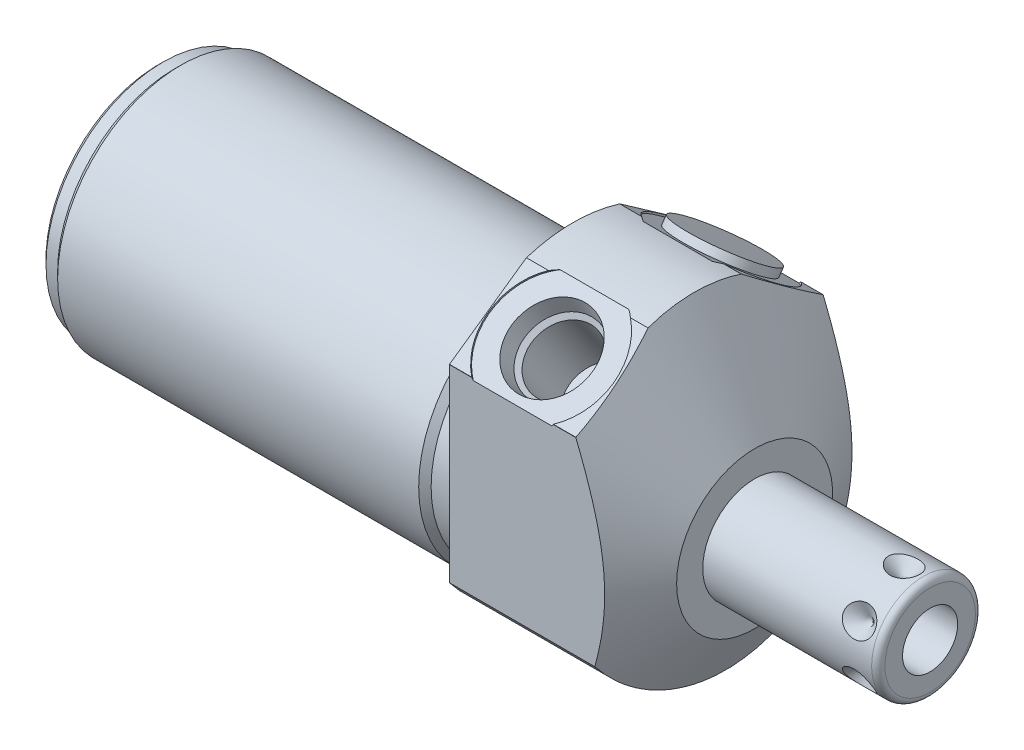
from build123d import *

# Parameters (mm, degrees)
SKETCH1_R           = 23.8125
EXTRUDE1_DEPTH      = 27.7876
EXTRUDE1_DEPTH_BACK = 63.5
CUT_EXTRUDE1_REACH  = 65.5
SKETCH2_R           = 23.8125
SKETCH2_R_2         = 18.8595
CUT_EXTRUDE3_START  = -27.7876
SKETCH4_R           = 28.575
CUT_EXTRUDE3_DEPTH  = 27.7876
SKETCH18_R          = 9.525
CUT_EXTRUDE4_DEPTH  = 0.254
SKETCH19_R          = 9.525
CUT_EXTRUDE5_DEPTH  = 0.254
CHAMFER1_SIZE       = 0.762
SKETCH15_R          = 6.9469
EXTRUDE2_DEPTH      = 1.27
CIRPATTERN1_COUNT   = 6


with BuildPart() as part:
    # Sketch1 → Extrude1 (new body, two sides)
    with BuildSketch(Plane(origin=(0, 0, 0), x_dir=(0, 0, -1), z_dir=(1, 0, 0))) as extrude1_sk:
        Circle(SKETCH1_R)
    extrude(amount=EXTRUDE1_DEPTH)
    extrude(extrude1_sk.sketch, amount=-EXTRUDE1_DEPTH_BACK)

    # Sketch2 → Cut-Extrude1 (cut, up to next)
    with BuildSketch(Plane(origin=(0, 0, 0), x_dir=(0, 0, -1), z_dir=(1, 0, 0)), mode=Mode.PRIVATE) as cut_extrude1_sk1:
        Circle(SKETCH2_R)
        with Locations((0, -4.191)):
            Circle(SKETCH2_R_2, mode=Mode.SUBTRACT)
    cut_extrude1_tool1 = extrude(cut_extrude1_sk1.sketch, amount=-CUT_EXTRUDE1_REACH, mode=Mode.PRIVATE) & part.part
    add(cut_extrude1_tool1.solids().sort_by_distance((0, 0, 23.138981))[0], mode=Mode.SUBTRACT)

    # Sketch4 → Cut-Extrude3 (cut)
    with BuildSketch(Plane.ZY.offset(CUT_EXTRUDE3_START)):
        Circle(SKETCH4_R)
        with BuildLine():
            Line((18.923, -14.455283714), (18.923, 14.465869871))
            Line((18.923, 14.465869871), (0, 27.715897117))
            Line((0, 27.715897117), (-18.923, 14.465869871))
            Line((-18.923, 14.465869871), (-18.923, -14.455283714))
            ThreePointArc((-18.923, -14.455283714), (0, -23.8125), (18.923, -14.455283714))
        make_face(mode=Mode.SUBTRACT)
    extrude(amount=CUT_EXTRUDE3_DEPTH, mode=Mode.SUBTRACT)

    # Sketch6 → Cut-Revolve2 (revolve, cut)
    with BuildSketch(Plane.XY, mode=Mode.PRIVATE) as cut_revolve2_sk:
        Polygon((4.764025965, 47.625), (27.7876, 7.747), (27.7876, 47.625), align=None)
    revolve(cut_revolve2_sk.sketch.rotate(Axis((3.612847264, -4.191, 0), (1, 0, 0)), 270), axis=Axis((3.612847264, -4.191, 0), (1, 0, 0)), mode=Mode.SUBTRACT)  # turned: the seam where the file's is

    # S2D0002 → Cut-Revolve3 (revolve, cut)
    with BuildSketch(Plane(origin=(9.652, 18.394824642, 12.869035589), x_dir=(0, 0.573576436, -0.819152044), z_dir=(1, 0, 0))):
        Polygon((0, 0), (6.1849, 0), (5.642306865, -2.5527), (4.9784, -3.216606865), (4.9784, -13.462), (0, -13.462), align=None)
    revolve(axis=Axis((9.652, 6.816028581, 4.761475303), (0, 0.819152044, 0.573576436)), mode=Mode.SUBTRACT)

    # Sketch8 → Cut-Revolve4 (revolve, cut)
    with BuildSketch(Plane(origin=(9.652, 18.394824642, -12.869035589), x_dir=(0, -0.573576436, -0.819152044), z_dir=(1, 0, 0))):
        Polygon((0, 0), (6.1849, 0), (5.642306865, -2.5527), (4.9784, -3.216606865), (4.9784, -13.462), (0, -13.462), align=None)
    revolve(axis=Axis((9.652, 6.816028581, -4.761475303), (0, 0.819152044, -0.573576436)), mode=Mode.SUBTRACT)

    # Sketch18 → Cut-Extrude4 (cut)
    with BuildSketch(Plane(origin=(0, 18.59764611, 13.022211999), x_dir=(1, 0, 0), z_dir=(0, 0.819152044, 0.573576436))):
        with Locations((9.652, 0.009141155)):
            Circle(SKETCH18_R)
    extrude(amount=-CUT_EXTRUDE4_DEPTH, mode=Mode.SUBTRACT)

    # Sketch19 → Cut-Extrude5 (cut)
    with BuildSketch(Plane(origin=(0, 18.59764611, -13.022211999), x_dir=(1, 0, 0), z_dir=(0, 0.819152044, -0.573576436))):
        with Locations((9.652, -0.009141155)):
            Circle(SKETCH19_R)
    extrude(amount=-CUT_EXTRUDE5_DEPTH, mode=Mode.SUBTRACT)

    # Sketch10 → Cut-Revolve6 (revolve, cut)
    with BuildSketch(Plane.XY, mode=Mode.PRIVATE) as cut_revolve6_sk:
        Polygon((0, 14.6685), (0, 13.716), (-3.81, 13.716), (-4.7625, 14.6685), align=None)
    revolve(cut_revolve6_sk.sketch.rotate(Axis((-5.000625, -4.191, 0), (1, 0, 0)), 90), axis=Axis((-5.000625, -4.191, 0), (1, 0, 0)), mode=Mode.SUBTRACT)  # turned: the seam where the file's is

    # Sketch12 → Cut-Revolve8 (revolve, cut)
    with BuildSketch(Plane.XY, mode=Mode.PRIVATE) as cut_revolve8_sk:
        Polygon((-63.5, 14.6685), (-63.5, 13.716), (-60.96, 13.716), (-60.0075, 14.6685), align=None)
    revolve(cut_revolve8_sk.sketch.rotate(Axis((-63.674625, -4.191, 0), (1, 0, 0)), 90), axis=Axis((-63.674625, -4.191, 0), (1, 0, 0)), mode=Mode.SUBTRACT)  # turned: the seam where the file's is

    # Chamfer1
    chamfer1_edges = [part.edges().sort_by_distance(p)[0] for p in [
        (-63.5, -4.191, -17.907),
    ]]
    chamfer(chamfer1_edges, length=CHAMFER1_SIZE)

    # Sketch13 → Revolve1 (revolve)
    with BuildSketch(Plane(origin=(0, 0, 0), x_dir=(0, -1, 0), z_dir=(0, 0, 1)), mode=Mode.PRIVATE) as revolve1_sk:
        with BuildLine():
            Line((4.191, 27.7876), (4.191, 54.6354))
            Line((4.191, 54.6354), (11.1125, 54.6354))
            ThreePointArc((11.1125, 54.6354), (11.83092049, 54.33782049), (12.1285, 53.6194))
            Line((12.1285, 53.6194), (12.1285, 27.7876))
            Line((12.1285, 27.7876), (4.191, 27.7876))
        make_face()
    revolve(revolve1_sk.sketch.rotate(Axis((26.44521, -4.191, 0), (1, 0, 0)), 270), axis=Axis((26.44521, -4.191, 0), (1, 0, 0)))  # turned: the seam where the file's is

    # S2D0001 → Cut-Revolve9 (revolve, cut)
    with BuildSketch(Plane(origin=(54.6354, -8.4074, 0), x_dir=(0, -1, 0), z_dir=(0, 0, 1)), mode=Mode.PRIVATE) as cut_revolve9_sk:
        Polygon((0, 0), (0, -15.24), (-4.2164, -17.773468714), (-4.2164, 0), align=None)
    revolve(cut_revolve9_sk.sketch.rotate(Axis((35.97325785, -4.191, 0), (1, 0, 0)), 270), axis=Axis((35.97325785, -4.191, 0), (1, 0, 0)), mode=Mode.SUBTRACT)  # turned: the seam where the file's is

    # Sketch15 → Extrude2 (add)
    with BuildSketch(Plane(origin=(27.7876, 18.389581491, -12.876523585), x_dir=(0, -0.573576436, -0.819152044), z_dir=(0, -0.819152044, 0.573576436))):
        with Locations((-0.009141155, -18.1356)):
            Circle(SKETCH15_R)
    extrude(amount=-EXTRUDE2_DEPTH)

    # Sketch16 → Cut-Revolve10 (revolve, cut)
    with BuildSketch(Plane(origin=(50.673, 3.7465, 0), x_dir=(-1, 0, 0), z_dir=(0, 0, -1)), mode=Mode.PRIVATE) as cut_revolve10_sk:
        Polygon((0, 0), (2.413, 0), (0, -2.413), align=None)
    cut_revolve10 = revolve(cut_revolve10_sk.sketch.rotate(Axis((50.673, -1.324519499, 0), (0, 1, 0)), 90), axis=Axis((50.673, -1.324519499, 0), (0, 1, 0)), mode=Mode.SUBTRACT)  # turned: the seam where the file's is

    # CirPattern1: Cut-Revolve10 ×6 about axis
    cirpattern1_axis = Axis((26.44521, -4.191, 0), (-1, 0, 0))
    for i in range(1, CIRPATTERN1_COUNT):
        add(cut_revolve10.rotate(cirpattern1_axis, i * 360 / CIRPATTERN1_COUNT), mode=Mode.SUBTRACT)


solid = part.part
